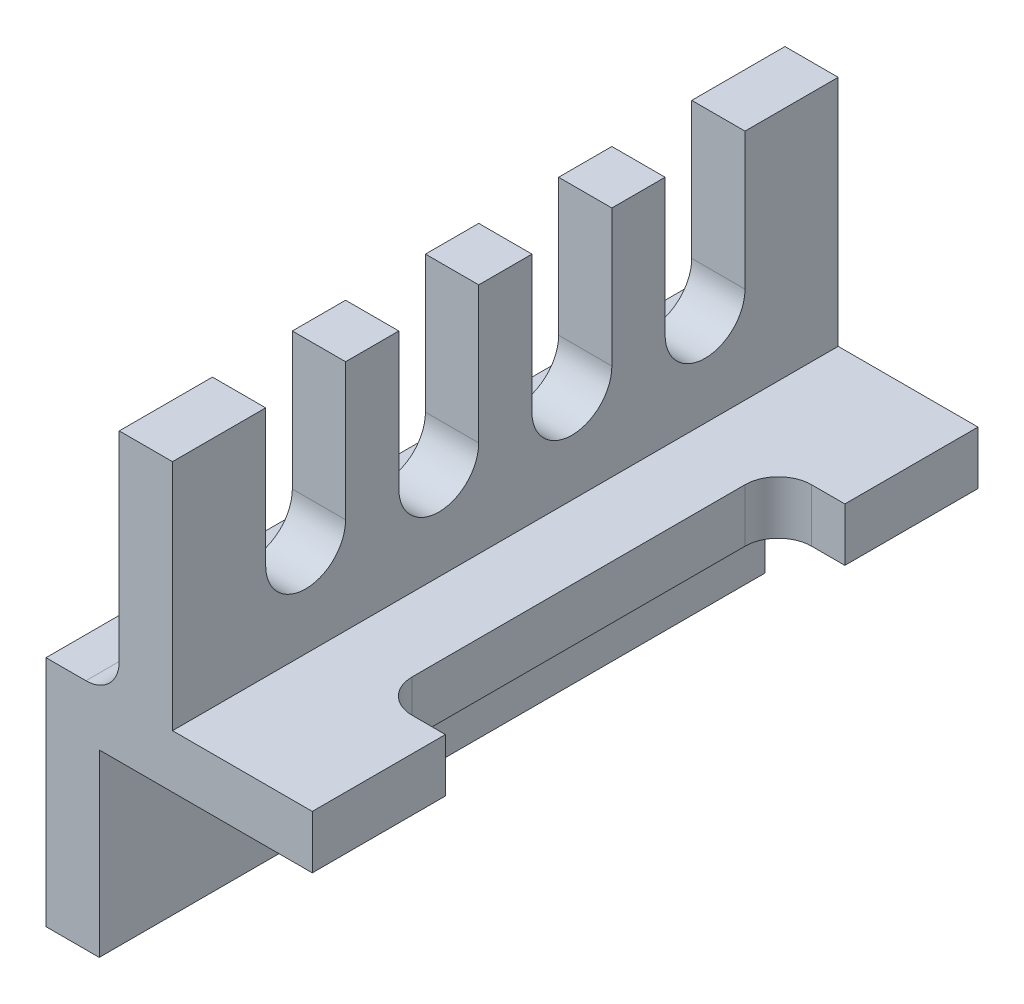
from build123d import *

# Parameters (mm, degrees)
BOSS_EXTRUDE1_DEPTH = 100
SKETCH3_W           = 10
SKETCH3_H           = 60
CUT_EXTRUDE1_DEPTH  = 8
CUT_EXTRUDE2_DEPTH  = 8
LPATTERN1_COUNT     = 4
LPATTERN1_PITCH     = 20
FILLET1_R           = 5


with BuildPart() as part:
    # Sketch2 → Boss-Extrude1 (new body)
    with BuildSketch(Plane.XY):
        Polygon((0, 0), (0, -35), (8, -35), (8, -8), (40, -8), (40, 0), (19, 0), (19, 35), (11, 35), (11, 0), align=None)
    extrude(amount=BOSS_EXTRUDE1_DEPTH)

    # Sketch3 → Cut-Extrude1 (cut)
    with BuildSketch(Plane(origin=(0, 0, 0), x_dir=(1, 0, 0), z_dir=(0, 1, 0))):
        with Locations((35, -50)):
            Rectangle(SKETCH3_W, SKETCH3_H)
    extrude(amount=-CUT_EXTRUDE1_DEPTH, mode=Mode.SUBTRACT)

    # Sketch4 → Cut-Extrude2 (cut)
    with BuildSketch(Plane(origin=(19, 0, 0), x_dir=(0, 0, -1), z_dir=(1, 0, 0))):
        with BuildLine():
            Line((-86, 35), (-86, 14.440154261))
            ThreePointArc((-86, 14.440154261), (-80, 8.440154261), (-74, 14.440154261))
            Line((-74, 14.440154261), (-74, 35))
            Line((-74, 35), (-86, 35))
        make_face()
    cut_extrude2 = extrude(amount=-CUT_EXTRUDE2_DEPTH, mode=Mode.SUBTRACT)

    # LPattern1: Cut-Extrude2 ×4
    with Locations(*[(0, 0, -i * LPATTERN1_PITCH) for i in range(1, LPATTERN1_COUNT)]):
        add(cut_extrude2, mode=Mode.SUBTRACT)

    # Fillet1
    fillet1_edges = [part.edges().sort_by_distance(p)[0] for p in [
        (11, 0, 50),
        (30, -4, 80),
        (30, -4, 20),
    ]]
    fillet(fillet1_edges, radius=FILLET1_R)


solid = part.part
